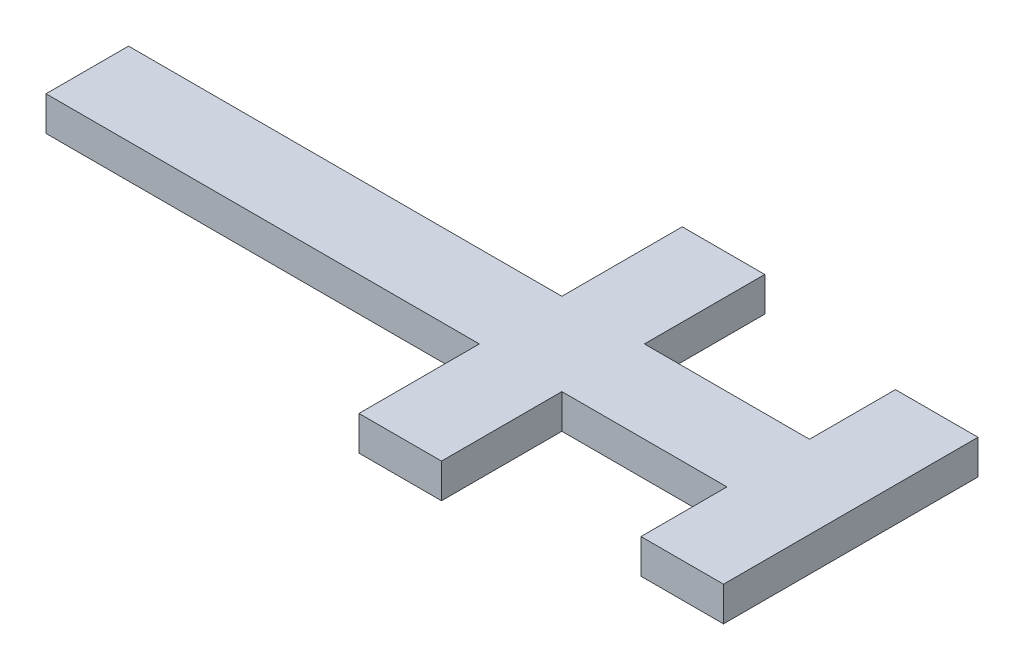
from build123d import *

# Parameters (mm, degrees)
SKETCH_3_W           = 10
SKETCH_3_H           = 35
SKETCH_3_W_2         = 26
SKETCH_3_H_2         = 10
SKETCH_3_W_3         = 38
SKETCH_3_W_4         = 25
EXTRUDE_1_DEPTH      = 1
EXTRUDE_2_DEPTH      = 4
EXTRUDE_2_DEPTH_BACK = 1
SKETCH_5_W           = 25
SKETCH_5_H           = 10
SKETCH_5_W_2         = 10
SKETCH_5_H_2         = 35
EXTRUDE_3_DEPTH      = 2


with BuildPart() as part:
    # 草图3 → 凸台-拉伸1 (new body)
    with BuildSketch(Plane(origin=(0, 0, 0), x_dir=(1, 0, 0), z_dir=(0, 1, 0))):
        with Locations((19, 0)):
            Rectangle(SKETCH_3_W, SKETCH_3_H)
        with Locations((1, 0)):
            Rectangle(SKETCH_3_W_2, SKETCH_3_H_2)
        Polygon((-12, -5), (-12, 5), (-12, 22.5), (-22, 22.5), (-22, 5), (-22, -5), (-22, -22.5), (-12, -22.5), align=None)
        with Locations((-41, 0)):
            Rectangle(SKETCH_3_W_3, SKETCH_3_H_2)
        with Locations((-72.5, 0)):
            Rectangle(SKETCH_3_W_4, SKETCH_3_H_2)
    extrude(amount=EXTRUDE_1_DEPTH)

    # 草图4 → 凸台-拉伸2 (add, two sides)
    with BuildSketch(Plane.XZ) as extrude_2_sk:
        Polygon((13, -18.5), (25, -18.5), (25, 18.5), (13, 18.5), (13, 6), (-11, 6), (-11, 23.5), (-23, 23.5), (-23, 6), (-86, 6), (-86, -6), (-23, -6), (-23, -23.5), (-11, -23.5), (-11, -6), (13, -6), align=None)
        Polygon((14, -17.5), (24, -17.5), (24, 17.5), (14, 17.5), (14, 5), (-12, 5), (-12, 22.5), (-22, 22.5), (-22, 5), (-85, 5), (-85, -5), (-22, -5), (-22, -22.5), (-12, -22.5), (-12, -5), (14, -5), align=None, mode=Mode.SUBTRACT)
    extrude(amount=EXTRUDE_2_DEPTH)
    extrude(extrude_2_sk.sketch, amount=-EXTRUDE_2_DEPTH_BACK)

    # 草图5 → 凸台-拉伸3 (add)
    with BuildSketch(Plane.XZ):
        Polygon((-22, 22.5), (-22, 5), (-20, 5), (-20, -5), (-22, -5), (-22, -22.5), (-12, -22.5), (-12, -5), (-14, -5), (-14, 5), (-12, 5), (-12, 22.5), align=None)
        with Locations((-72.5, 0)):
            Rectangle(SKETCH_5_W, SKETCH_5_H)
        with Locations((19, 0)):
            Rectangle(SKETCH_5_W_2, SKETCH_5_H_2)
    extrude(amount=EXTRUDE_3_DEPTH)


solid = part.part
